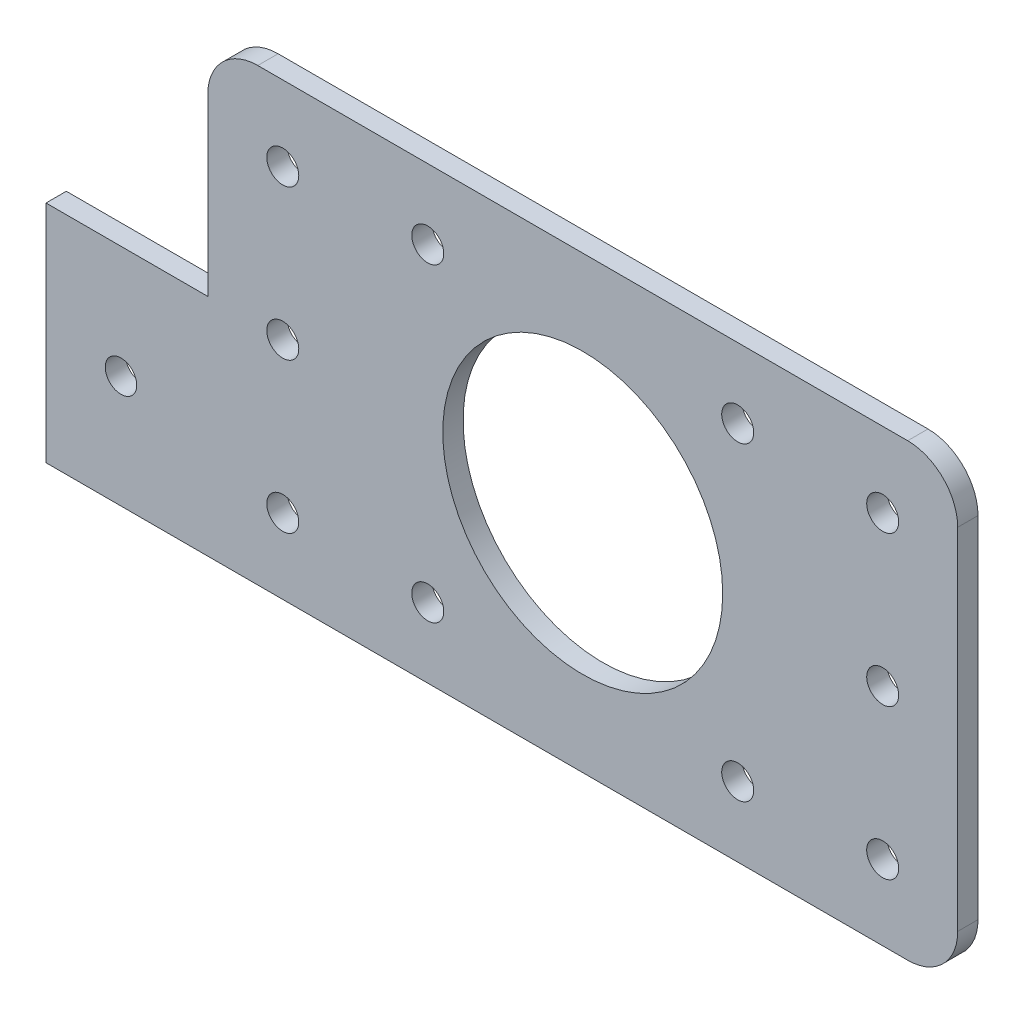
from build123d import *

# Parameters (mm, degrees)
SKETCH1_W               = 75
SKETCH1_H               = 45
SKETCH1_R               = 14
SKETCH1_R_2             = 1.6
BOSS_EXTRUDE1_DEPTH     = 2.032
FILLET2_R               = 5
SKETCH2_R               = 1.6
CUT_EXTRUDE1_DEPTH      = 3.032
SKETCH4_W               = 21.18
SKETCH4_H               = 22.5
BOSS_EXTRUDE2_DEPTH     = 2.032
MOUNTING_HOLE_SKETCH_R  = 1.575
MOUNTING_HOLE_CUT_DEPTH = 3.032


with BuildPart() as part:
    # Sketch1 → Boss-Extrude1 (new body)
    with BuildSketch(Plane.XY):
        Rectangle(SKETCH1_W, SKETCH1_H)
        Circle(SKETCH1_R, mode=Mode.SUBTRACT)
        with Locations((-15.5, 15.5)):
            Circle(SKETCH1_R_2, mode=Mode.SUBTRACT)
        with Locations((15.5, 15.5)):
            Circle(SKETCH1_R_2, mode=Mode.SUBTRACT)
        with Locations((15.5, -15.5)):
            Circle(SKETCH1_R_2, mode=Mode.SUBTRACT)
        with Locations((-15.5, -15.5)):
            Circle(SKETCH1_R_2, mode=Mode.SUBTRACT)
    extrude(amount=BOSS_EXTRUDE1_DEPTH)

    # Fillet2
    fillet2_edges = [part.edges().sort_by_distance(p)[0] for p in [
        (37.5, -22.5, 1.016),
        (-37.5, -22.5, 1.016),
        (-37.5, 22.5, 1.016),
        (37.5, 22.5, 1.016),
    ]]
    fillet(fillet2_edges, radius=FILLET2_R)

    # Sketch2 → Cut-Extrude1 (cut, through all)
    with BuildSketch(Plane.XY.offset(2.032)):
        with Locations((-30, 0)):
            Circle(SKETCH2_R)
        with Locations((-30, 15)):
            Circle(SKETCH2_R)
        with Locations((-30, -15)):
            Circle(SKETCH2_R)
        with Locations((30, -15)):
            Circle(SKETCH2_R)
        with Locations((30, 15)):
            Circle(SKETCH2_R)
        with Locations((30, 0)):
            Circle(SKETCH2_R)
    extrude(amount=-CUT_EXTRUDE1_DEPTH, mode=Mode.SUBTRACT)

    # Sketch4 → Boss-Extrude2 (add)
    with BuildSketch(Plane(origin=(0, 0, 0), x_dir=(-1, 0, 0), z_dir=(0, 0, -1))):
        with Locations((43.09, -11.25)):
            Rectangle(SKETCH4_W, SKETCH4_H)
    extrude(amount=-BOSS_EXTRUDE2_DEPTH)

    # Mounting Hole Sketch → Mounting Hole Cut (cut, through all)
    with BuildSketch(Plane.XY.offset(2.032)):
        with Locations((-46.18, -11.25)):
            Circle(MOUNTING_HOLE_SKETCH_R)
    extrude(amount=-MOUNTING_HOLE_CUT_DEPTH, mode=Mode.SUBTRACT)


solid = part.part
